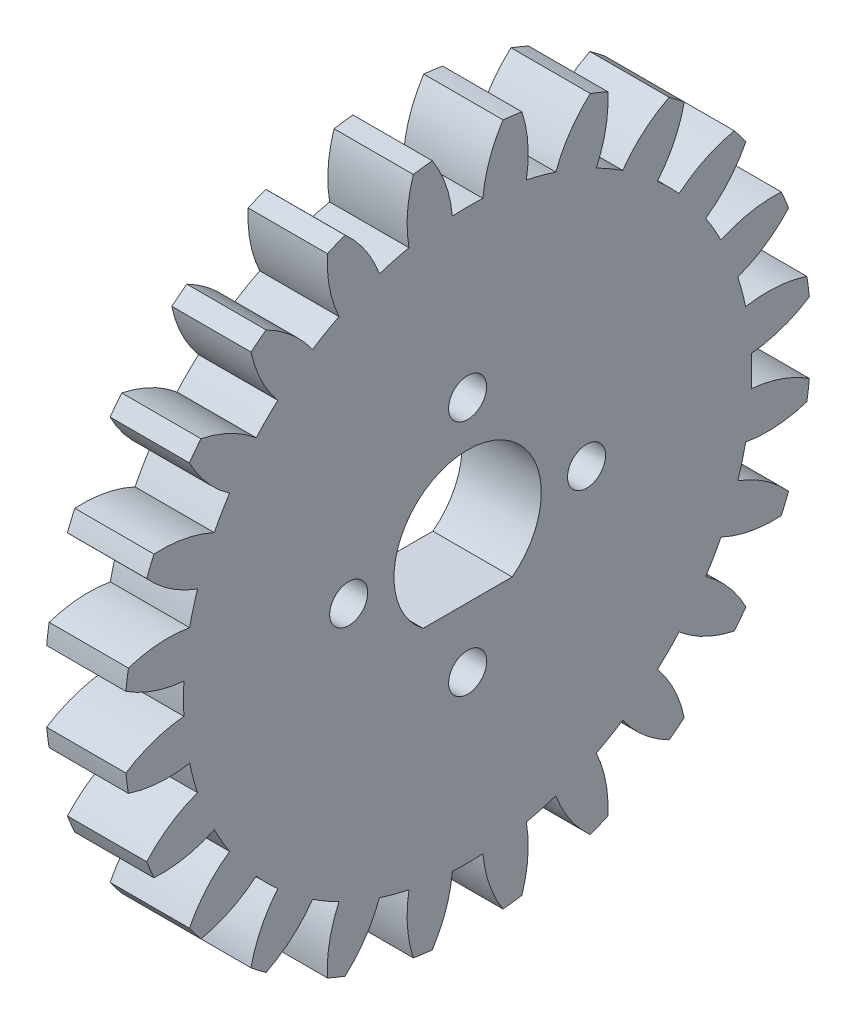
from build123d import *

# Parameters (mm, degrees)
BASPROSKE_W        = 3.175
BASPROSKE_H        = 13.758333333
TOOTHCUT_DEPTH     = 4.175
TEETHCUTS_COUNT    = 24
TEETHCUTS_ANGLE    = 345
CUT_EXTRUDE1_REACH = 5.175
CUT_EXTRUDE2_REACH = 5.175
SKETCH3_R          = 0.762


with BuildPart() as part:
    # BasProSke → Base-Revolve (revolve)
    with BuildSketch(Plane(origin=(0, 0, 0), x_dir=(1, 0, 0), z_dir=(0, 1, 0))):
        with Locations((1.5875, 6.879166667)):
            Rectangle(BASPROSKE_W, BASPROSKE_H)
    revolve(axis=Axis((-10, 0, 0), (1, 0, 0)))

    # TooCutSke → ToothCut (cut, through all)
    with BuildSketch(Plane(origin=(0, 0, 0), x_dir=(0, 0, -1), z_dir=(1, 0, 0))):
        with BuildLine():
            ThreePointArc((0.61154538, 11.362755163), (0, 11.3792), (-0.61154538, 11.362755163))
            ThreePointArc((-0.61154538, 11.362755163), (-0.876237748, 12.586912754), (-1.432393192, 13.709104797))
            ThreePointArc((-1.432393192, 13.709104797), (0, 13.783733333), (1.432393192, 13.709104797))
            ThreePointArc((1.432393192, 13.709104797), (0.876237748, 12.586912754), (0.61154538, 11.362755163))
        make_face()
    toothcut = extrude(amount=TOOTHCUT_DEPTH, mode=Mode.SUBTRACT)

    # TeethCuts: ToothCut ×24 about axis
    teethcuts_axis = Axis((-10, 0, 0), (1, 0, 0))
    for i in range(1, TEETHCUTS_COUNT):
        add(toothcut.rotate(teethcuts_axis, i * TEETHCUTS_ANGLE / (TEETHCUTS_COUNT - 1)), mode=Mode.SUBTRACT)

    # Sketch1 → Cut-Extrude1 (cut, up to next)
    with BuildSketch(Plane(origin=(3.175, 0, 0), x_dir=(0, 0, -1), z_dir=(1, 0, 0)), mode=Mode.PRIVATE) as cut_extrude1_sk1:
        with BuildLine():
            Line((-1.78325545, -2.35), (1.78325545, -2.35))
            ThreePointArc((1.78325545, -2.35), (0, 2.95), (-1.78325545, -2.35))
        make_face()
    cut_extrude1_tool1 = extrude(cut_extrude1_sk1.sketch, amount=-CUT_EXTRUDE1_REACH, mode=Mode.PRIVATE) & part.part
    add(cut_extrude1_tool1.solids().sort_by_distance((3.175, 0.146071, 0))[0], mode=Mode.SUBTRACT)

    # Sketch3 → Cut-Extrude2 (cut, up to next)
    with BuildSketch(Plane(origin=(3.175, 0, 0), x_dir=(0, 0, -1), z_dir=(1, 0, 0)), mode=Mode.PRIVATE) as cut_extrude2_sk1:
        with Locations((0, 4.7625)):
            Circle(SKETCH3_R)
    cut_extrude2_tool1 = extrude(cut_extrude2_sk1.sketch, amount=-CUT_EXTRUDE2_REACH, mode=Mode.PRIVATE) & part.part
    add(cut_extrude2_tool1.solids().sort_by_distance((3.175, 4.7625, 0))[0], mode=Mode.SUBTRACT)
    # Sketch3 → Cut-Extrude2 (cut, up to next)
    with BuildSketch(Plane(origin=(3.175, 0, 0), x_dir=(0, 0, -1), z_dir=(1, 0, 0)), mode=Mode.PRIVATE) as cut_extrude2_sk2:
        with Locations((-4.7625, 0)):
            Circle(SKETCH3_R)
    cut_extrude2_tool2 = extrude(cut_extrude2_sk2.sketch, amount=-CUT_EXTRUDE2_REACH, mode=Mode.PRIVATE) & part.part
    add(cut_extrude2_tool2.solids().sort_by_distance((3.175, 0, 4.7625))[0], mode=Mode.SUBTRACT)
    # Sketch3 → Cut-Extrude2 (cut, up to next)
    with BuildSketch(Plane(origin=(3.175, 0, 0), x_dir=(0, 0, -1), z_dir=(1, 0, 0)), mode=Mode.PRIVATE) as cut_extrude2_sk3:
        with Locations((4.7625, 0)):
            Circle(SKETCH3_R)
    cut_extrude2_tool3 = extrude(cut_extrude2_sk3.sketch, amount=-CUT_EXTRUDE2_REACH, mode=Mode.PRIVATE) & part.part
    add(cut_extrude2_tool3.solids().sort_by_distance((3.175, 0, -4.7625))[0], mode=Mode.SUBTRACT)
    # Sketch3 → Cut-Extrude2 (cut, up to next)
    with BuildSketch(Plane(origin=(3.175, 0, 0), x_dir=(0, 0, -1), z_dir=(1, 0, 0)), mode=Mode.PRIVATE) as cut_extrude2_sk4:
        with Locations((0, -4.7625)):
            Circle(SKETCH3_R)
    cut_extrude2_tool4 = extrude(cut_extrude2_sk4.sketch, amount=-CUT_EXTRUDE2_REACH, mode=Mode.PRIVATE) & part.part
    add(cut_extrude2_tool4.solids().sort_by_distance((3.175, -4.7625, 0))[0], mode=Mode.SUBTRACT)


solid = part.part
